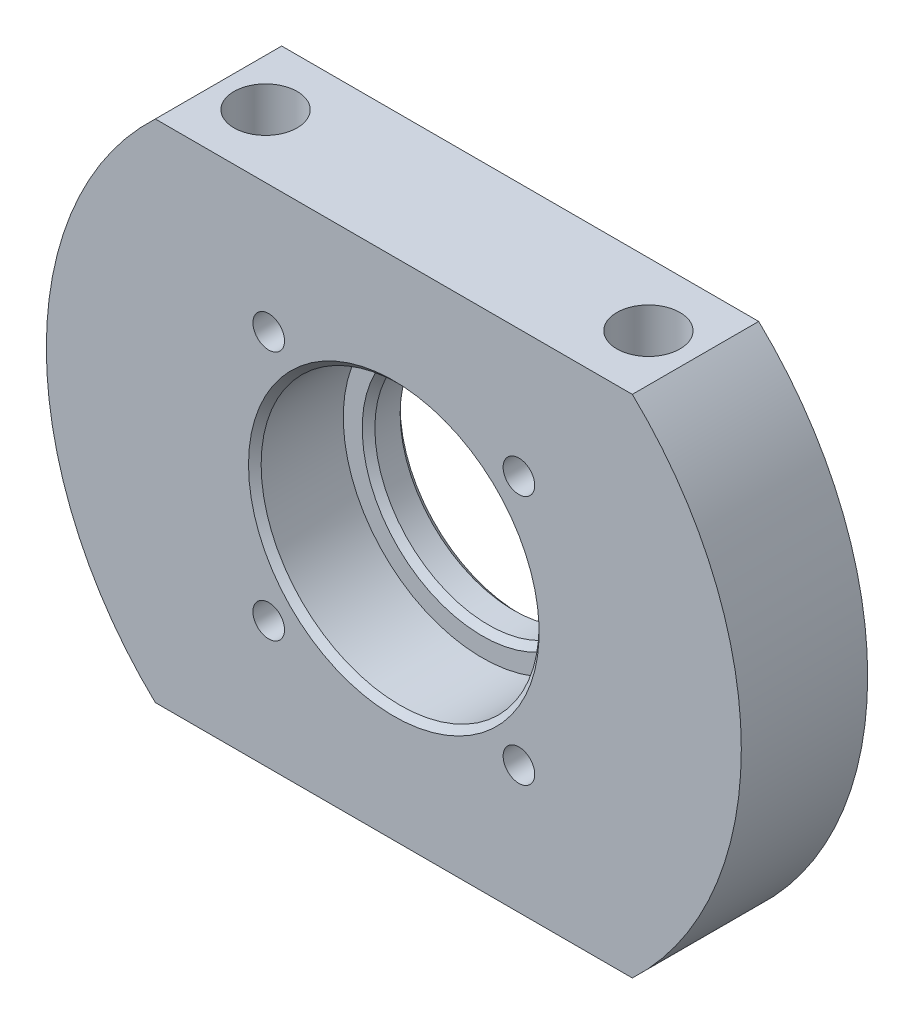
from build123d import *

# Parameters (mm, degrees)
ESQUISSE1_R             = 9
EXTRUSION1_DEPTH        = 10
ESQUISSE2_R             = 11
ENL_V_MAT_EXTRU_1_DEPTH = 7
CHANFREIN1_SIZE         = 0.5
TROU_TARAUD_M31_D       = 2.5
TROU_TARAUD_M31_DEPTH   = 10
ESQUISSE7_R             = 2.5
ENL_V_MAT_EXTRU_2_DEPTH = 41


with BuildPart() as part:
    # Esquisse1 → Extrusion1 (new body)
    with BuildSketch(Plane.XY):
        with BuildLine():
            Line((0, 0), (37.749172176, 0))
            ThreePointArc((37.749172176, 0), (46.374586088, 20), (37.749172176, 40))
            Line((37.749172176, 40), (0, 40))
            ThreePointArc((0, 40), (-8.625413912, 20), (0, 0))
        make_face()
        with Locations((18.874586088, 20)):
            Circle(ESQUISSE1_R, mode=Mode.SUBTRACT)
    extrude(amount=EXTRUSION1_DEPTH)

    # Esquisse2 → Enlèv. mat.-Extru.1 (cut)
    with BuildSketch(Plane.XY.offset(10)):
        with Locations((18.874586088, 20)):
            Circle(ESQUISSE2_R)
    extrude(amount=-ENL_V_MAT_EXTRU_1_DEPTH, mode=Mode.SUBTRACT)

    # Chanfrein1
    chanfrein1_edges = [part.edges().sort_by_distance(p)[0] for p in [
        (9.874586088, 20, 0),
        (9.874586088, 20, 3),
        (7.874586088, 20, 10),
    ]]
    chamfer(chanfrein1_edges, length=CHANFREIN1_SIZE)

    # Trou taraudé M31
    with Locations(Plane.XY.offset(10)):
        with Locations((28.774081025, 29.899494937), (8.975091152, 29.899494937), (8.975091152, 10.100505063), (28.774081025, 10.100505063)):
            Hole(TROU_TARAUD_M31_D / 2, depth=TROU_TARAUD_M31_DEPTH)

    # Esquisse7 → Enlèv. mat.-Extru.2 (cut, through all)
    with BuildSketch(Plane(origin=(0, 40, 0), x_dir=(1, 0, 0), z_dir=(0, 1, 0))):
        with Locations((3.725091152, -5)):
            Circle(ESQUISSE7_R)
        with Locations((34.024081025, -5)):
            Circle(ESQUISSE7_R)
    extrude(amount=-ENL_V_MAT_EXTRU_2_DEPTH, mode=Mode.SUBTRACT)


solid = part.part
